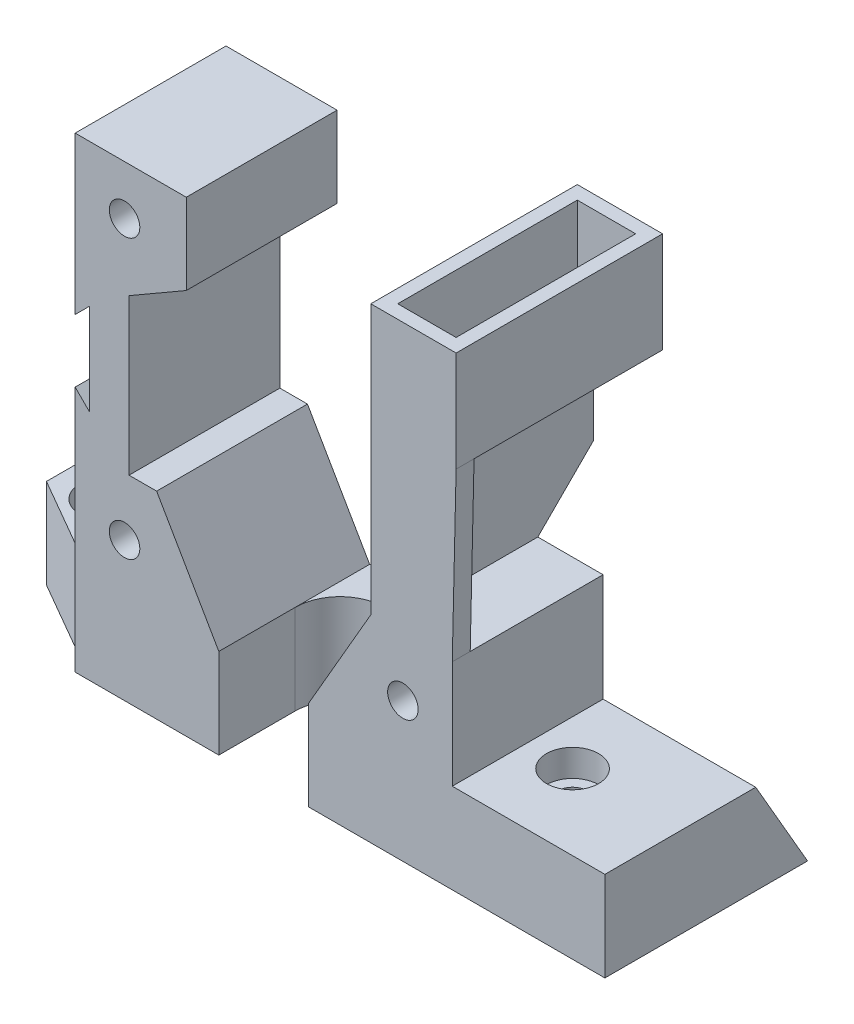
from build123d import *

# Parameters (mm, degrees)
SKETCH1_R                       = 1.7
BOSS_EXTRUDE1_DEPTH             = 16.8
BOSS_EXTRUDE2_DEPTH             = 17
BOSS_EXTRUDE2_DEPTH_BACK        = 42
SKETCH3_W                       = 16.8
SKETCH3_H                       = 10
BOSS_EXTRUDE3_DEPTH             = 10
SKETCH4_R                       = 1.7
CUT_EXTRUDE1_DEPTH              = 11
SKETCH4_3_R                     = 2.9
SKETCH4_3_R_2                   = 1.7
CUT_EXTRUDE2_DEPTH              = 3
CUT_EXTRUDE3_START              = -16.8
SKETCH6_R                       = 2.9
CUT_EXTRUDE3_DEPTH              = 2
CUT_EXTRUDE4_DEPTH              = 11
SKIZZE1_R                       = 5
SCHNITT_LINEAR_AUSTRAGEN1_DEPTH = 53
SCHNITT_LINEAR_AUSTRAGEN2_DEPTH = 17.8
AUFSATZ_LINEAR_AUSTRAGEN1_DEPTH = 16.8
SCHNITT_LINEAR_AUSTRAGEN3_DEPTH = 11
SKETCH13_W                      = 9.5
SKETCH13_H                      = 23
SKETCH13_W_2                    = 6.5
SKETCH13_H_2                    = 20
BOSS_EXTRUDE7_DEPTH             = 10.2
SKETCH14_W                      = 9.5
SKETCH14_H                      = 23
SKETCH14_W_2                    = 3.5
SKETCH14_H_2                    = 1
BOSS_EXTRUDE8_DEPTH             = 1
BOSS_EXTRUDE9_DEPTH             = 2
BOSS_EXTRUDE10_DEPTH            = 1.8
CUT_EXTRUDE10_DEPTH             = 17.8


with BuildPart() as part:
    # Sketch1 → Boss-Extrude1 (new body)
    with BuildSketch(Plane.XY):
        Polygon((-21, 21.339745962), (-21, -20.660254038), (21, -20.660254038), (21, -8.660254038), (15, -8.660254038), (0, -17.320508076), (-15, -8.660254038), (-15, 8.660254038), (-8.626933041, 12.339745962), (-8.626933041, 21.339745962), align=None)
        with Locations((-15.5, -15.160254038)):
            Circle(SKETCH1_R, mode=Mode.SUBTRACT)
        with Locations((15.5, -15.160254038)):
            Circle(SKETCH1_R, mode=Mode.SUBTRACT)
        with Locations((-15.5, 15.839745962)):
            Circle(SKETCH1_R, mode=Mode.SUBTRACT)
    extrude(amount=-BOSS_EXTRUDE1_DEPTH)



with BuildPart() as body_2:
    # Sketch2 → Boss-Extrude2 (new body, two sides)
    with BuildSketch(Plane(origin=(21, 0, 0), x_dir=(0, 0, -1), z_dir=(1, 0, 0))) as boss_extrude2_sk:
        Polygon((0, -20.660254038), (0, -30.660254038), (22.573502692, -30.660254038), (16.8, -20.660254038), align=None)
    extrude(amount=BOSS_EXTRUDE2_DEPTH)
    extrude(boss_extrude2_sk.sketch, amount=-BOSS_EXTRUDE2_DEPTH_BACK)


with BuildPart() as part_1:
    add(part.part)

    add(body_2.part)  # Boss-Extrude3 merges body 2
    # Sketch3 → Boss-Extrude3 (add)
    with BuildSketch(Plane.ZY.offset(21)):
        with Locations((-8.4, -25.660254038)):
            Rectangle(SKETCH3_W, SKETCH3_H)
    extrude(amount=BOSS_EXTRUDE3_DEPTH)

    # Sketch4 → Cut-Extrude1 (cut, through all)
    with BuildSketch(Plane(origin=(0, -20.660254038, 0), x_dir=(1, 0, 0), z_dir=(0, 1, 0))):
        with Locations(Location((-26, 8.4, 0), (0, 0, 270))):  # turned: the seam where the file's is
            Circle(SKETCH4_R)
        with Locations(Location((26, 8.4, 0), (0, 0, 270))):  # turned: the seam where the file's is
            Circle(SKETCH4_R)
    extrude(amount=-CUT_EXTRUDE1_DEPTH, mode=Mode.SUBTRACT)

    # Sketch4_3 → Cut-Extrude2 (cut)
    with BuildSketch(Plane(origin=(0, -20.660254038, 0), x_dir=(1, 0, 0), z_dir=(0, 1, 0))):
        with Locations(Location((-26, 8.4, 0), (0, 0, 270))):  # turned: the seam where the file's is
            Circle(SKETCH4_3_R)
        with Locations(Location((-26, 8.4, 0), (0, 0, 270))):  # turned: the seam where the file's is
            Circle(SKETCH4_3_R_2, mode=Mode.SUBTRACT)
        with Locations(Location((26, 8.4, 0), (0, 0, 90))):  # turned: the seam where the file's is
            Circle(SKETCH4_3_R)
        with Locations(Location((26, 8.4, 0), (0, 0, 270))):  # turned: the seam where the file's is
            Circle(SKETCH4_3_R_2, mode=Mode.SUBTRACT)
    extrude(amount=-CUT_EXTRUDE2_DEPTH, mode=Mode.SUBTRACT)

    # Sketch6 → Cut-Extrude3 (cut)
    with BuildSketch(Plane.XY.offset(CUT_EXTRUDE3_START)):
        with Locations((-15.5, 15.839745962)):
            Circle(SKETCH6_R)
        with Locations((-15.5, -15.160254038)):
            Circle(SKETCH6_R)
        with Locations((15.5, -15.160254038)):
            Circle(SKETCH6_R)
    extrude(amount=CUT_EXTRUDE3_DEPTH, mode=Mode.SUBTRACT)

    # Sketch5 → Cut-Extrude4 (cut, through all)
    with BuildSketch(Plane(origin=(0, -20.660254038, 0), x_dir=(1, 0, 0), z_dir=(0, 1, 0))):
        Polygon((-31, 0), (-31, 6.8), (-21, 1.026497308), (-21, 0), align=None)
    extrude(amount=-CUT_EXTRUDE4_DEPTH, mode=Mode.SUBTRACT)

    # Skizze1 → Schnitt-Linear austragen1 (cut, through all)
    with BuildSketch(Plane.XZ.offset(30.660254038)):
        with Locations((0, -8.5)):
            Circle(SKIZZE1_R)
    extrude(amount=-SCHNITT_LINEAR_AUSTRAGEN1_DEPTH, mode=Mode.SUBTRACT)

    # Skizze2 → Schnitt-Linear austragen2 (cut, through all)
    with BuildSketch(Plane(origin=(0, 0, -16.8), x_dir=(-1, 0, 0), z_dir=(0, 0, -1))):
        Polygon((-5, -20.660254038), (5, -20.660254038), (10.392304845, -11.320508076), (0, -17.320508076), (-10.392304845, -11.320508076), align=None)
    extrude(amount=-SCHNITT_LINEAR_AUSTRAGEN2_DEPTH, mode=Mode.SUBTRACT)

    # Skizze2_3 → Aufsatz-Linear austragen1 (add)
    with BuildSketch(Plane(origin=(0, 0, -16.8), x_dir=(-1, 0, 0), z_dir=(0, 0, -1))):
        Polygon((-15, -8.660254038), (-10.392304845, -11.320508076), (-11.92820323, -8.660254038), align=None)
        Polygon((11.92820323, -8.660254038), (10.392304845, -11.320508076), (15, -8.660254038), align=None)
    extrude(amount=-AUFSATZ_LINEAR_AUSTRAGEN1_DEPTH)

    # Skizze3 → Schnitt-Linear austragen3 (cut, through all)
    with BuildSketch(Plane(origin=(0, -20.660254038, 0), x_dir=(1, 0, 0), z_dir=(0, 1, 0))):
        with BuildLine():
            Line((5, 0), (-5, 0))
            Line((-5, 0), (-5, 8.5))
            ThreePointArc((-5, 8.5), (0, 3.5), (5, 8.5))
            Line((5, 8.5), (5, 0))
        make_face()
    extrude(amount=-SCHNITT_LINEAR_AUSTRAGEN3_DEPTH, mode=Mode.SUBTRACT)



with BuildPart() as body_2_2:
    # Sketch13 → Boss-Extrude7 (new body)
    with BuildSketch(Plane(origin=(0, 21.339745962, 0), x_dir=(1, 0, 0), z_dir=(0, 1, 0))):
        with Locations((16.67820323, 11.5)):
            Rectangle(SKETCH13_W, SKETCH13_H)
        with Locations((16.67820323, 11.5)):
            Rectangle(SKETCH13_W_2, SKETCH13_H_2, mode=Mode.SUBTRACT)
    extrude(amount=-BOSS_EXTRUDE7_DEPTH)

    # Sketch14 → Boss-Extrude8 (add)
    with BuildSketch(Plane.XZ.offset(-11.139745962)):
        with Locations((16.67820323, -11.5)):
            Rectangle(SKETCH14_W, SKETCH14_H)
        with Locations((16.67820323, -19.6)):
            Rectangle(SKETCH14_W_2, SKETCH14_H_2, mode=Mode.SUBTRACT)
        with Locations((16.67820323, -10.8)):
            Rectangle(SKETCH14_W_2, SKETCH14_H_2, mode=Mode.SUBTRACT)
        with Locations((16.67820323, -3.5)):
            Rectangle(SKETCH14_W_2, SKETCH14_H_2, mode=Mode.SUBTRACT)
    extrude(amount=BOSS_EXTRUDE8_DEPTH)


with BuildPart() as part_2:
    add(part_1.part)

    add(body_2_2.part)  # Boss-Extrude9 merges body 2 2
    # Sketch15 → Boss-Extrude9 (add)
    with BuildSketch(Plane.XY):
        Polygon((21.42820323, 10.139745962), (21, -8.660254038), (11.92820323, -8.660254038), (11.92820323, 10.139745962), align=None)
    extrude(amount=-BOSS_EXTRUDE9_DEPTH)

    # Sketch16 → Boss-Extrude10 (add)
    with BuildSketch(Plane.ZY.offset(-11.92820323)):
        Polygon((-2, 10.139745962), (-23, 10.139745962), (-23, -2.460254038), (-16.8, -8.660254038), (-2, -8.660254038), align=None)
    extrude(amount=-BOSS_EXTRUDE10_DEPTH)

    # Sketch18 → Cut-Extrude10 (cut, through all)
    with BuildSketch(Plane(origin=(0, 0, -16.8), x_dir=(-1, 0, 0), z_dir=(0, 0, -1))):
        Polygon((21, 0.339745962), (21, 3.839745962), (19.4, 5.439745962), (19.4, -4.760254038), (21, -3.160254038), align=None)
    extrude(amount=-CUT_EXTRUDE10_DEPTH, mode=Mode.SUBTRACT)


solid = part_2.part
